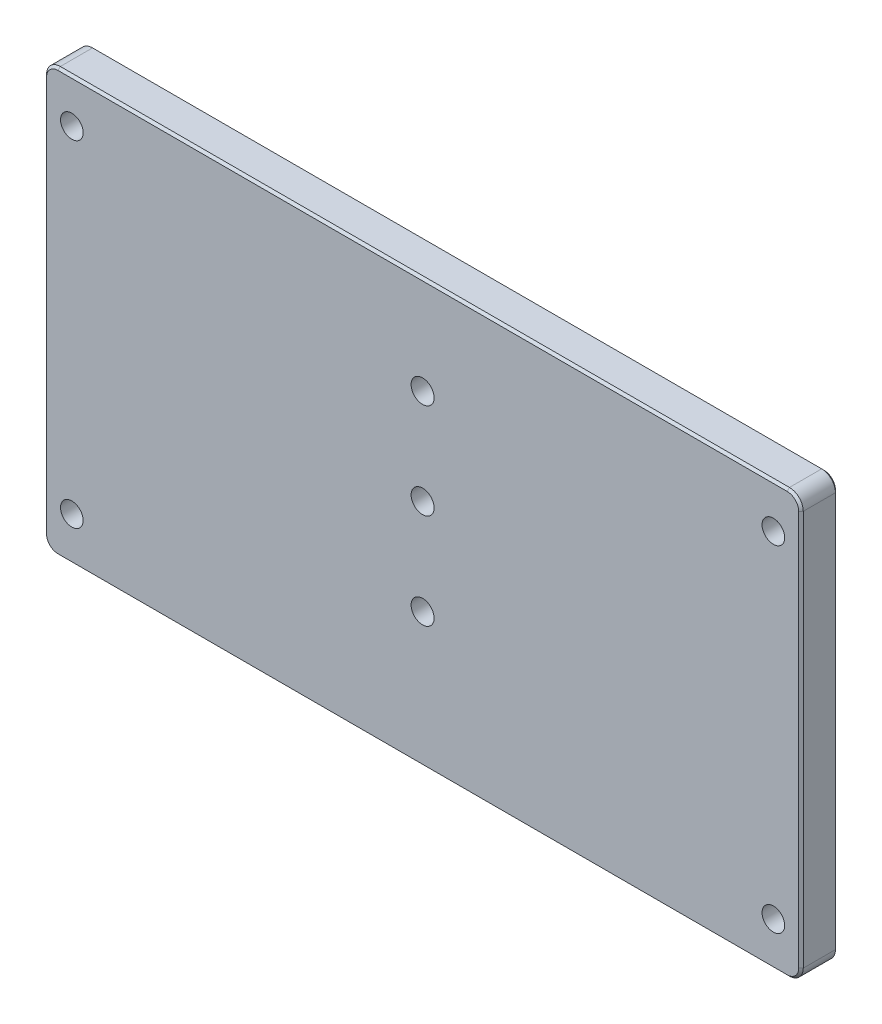
from build123d import *

# Parameters (mm, degrees)
SKETCH1_W             = 164.5
SKETCH1_H             = 92
BOSS_EXTRUDE1_DEPTH   = 8
HOLE1_D               = 4.917
HOLE2_D               = 4.917
FILLET1_R             = 3
CHAMFER2_SIZE         = 0.5
M6X1_0_TAPPED_HOLE1_D = 5


with BuildPart() as part:
    # Sketch1 → Boss-Extrude1 (new body)
    with BuildSketch(Plane.XY.offset(3)):
        Rectangle(SKETCH1_W, SKETCH1_H)
    extrude(amount=-BOSS_EXTRUDE1_DEPTH)

    # Hole1 (through all)
    with Locations(Plane(origin=(0, 0, -5), x_dir=(-1, 0, 0), z_dir=(0, 0, -1))):
        with Locations((-76.25, -36.5), (76.25, 36.5)):
            Hole(HOLE1_D / 2)

    # Hole2 (through all)
    with Locations(Plane.XY.offset(3)):
        with Locations((-76.25, -36.5), (76.25, 36.5)):
            Hole(HOLE2_D / 2)

    # Fillet1
    fillet1_edges = [part.edges().sort_by_distance(p)[0] for p in [
        (82.25, 46, -1),
        (82.25, -46, -1),
        (-82.25, -46, -1),
        (-82.25, 46, -1),
    ]]
    fillet(fillet1_edges, radius=FILLET1_R)

    # Chamfer2
    chamfer2_edges = [part.edges().sort_by_distance(p)[0] for p in [
        (0, 46, 3),
        (0, 46, -5),
        (-82.25, 0, 3),
        (0, -46, 3),
        (82.25, 0, 3),
        (81.371320344, -45.121320344, 3),
        (-81.371320344, -45.121320344, 3),
        (81.371320344, 45.121320344, 3),
        (-81.371320344, 45.121320344, 3),
        (-82.25, 0, -5),
        (82.25, 0, -5),
        (0, -46, -5),
        (81.371320344, -45.121320344, -5),
        (-81.371320344, -45.121320344, -5),
        (81.371320344, 45.121320344, -5),
        (-81.371320344, 45.121320344, -5),
    ]]
    chamfer(chamfer2_edges, length=CHAMFER2_SIZE)

    # M6x1.0 Tapped Hole1 (through all)
    with Locations(Plane.XY.offset(3)):
        with Locations((0, 24.75), (0, 4), (0, -16.75)):
            Hole(M6X1_0_TAPPED_HOLE1_D / 2)


solid = part.part
